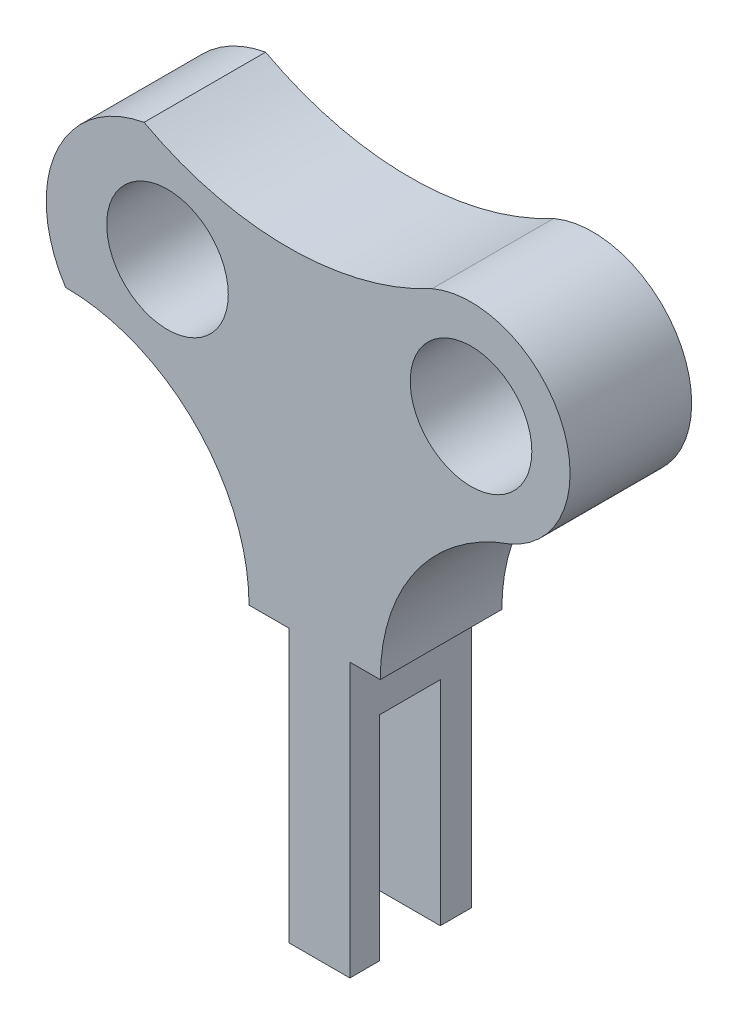
from build123d import *

# Parameters (mm, degrees)
SKETCH21_R           = 10
BOSS_EXTRUDE20_DEPTH = 20
SKETCH24_W           = 10.018971209
SKETCH24_H           = 35.052940056
CUT_EXTRUDE10_DEPTH  = 20


with BuildPart() as part:
    # Sketch21 → Boss-Extrude20 (new body)
    with BuildSketch(Plane.XY):
        with BuildLine():
            Line((54.893048592, 39.689392996), (64.893048592, 39.689392996))
            Line((64.893048592, 39.689392996), (64.893048592, 84.689392996))
            Line((64.893048592, 84.689392996), (69.893048592, 84.689392996))
            ThreePointArc((69.893048592, 84.689392996), (75.770400953, 103.092850807), (91.226612731, 114.683193669))
            ThreePointArc((91.226612731, 114.683193669), (99.80843011, 136.069116434), (78.422507345, 144.650933813))
            ThreePointArc((78.422507345, 144.650933813), (54.7296652, 138.68102842), (31.036823055, 144.650933813))
            ThreePointArc((31.036823055, 144.650933813), (16.541386166, 133.13054606), (18.132679452, 114.683193669))
            ThreePointArc((18.132679452, 114.683193669), (39.470310291, 105.844857587), (48.308646374, 84.507226748))
            Line((48.308646374, 84.507226748), (54.893048592, 84.507226748))
            Line((54.893048592, 84.507226748), (54.893048592, 39.689392996))
        make_face()
        with Locations((84.824560038, 129.667063741)):
            Circle(SKETCH21_R, mode=Mode.SUBTRACT)
        with Locations((34.893048592, 127.050928279)):
            Circle(SKETCH21_R, mode=Mode.SUBTRACT)
    extrude(amount=BOSS_EXTRUDE20_DEPTH)

    # Sketch24 → Cut-Extrude10 (cut)
    with BuildSketch(Plane.ZY.offset(-54.893048592)):
        with Locations((10.125179514, 57.215863024)):
            Rectangle(SKETCH24_W, SKETCH24_H)
    extrude(amount=-CUT_EXTRUDE10_DEPTH, mode=Mode.SUBTRACT)


solid = part.part
